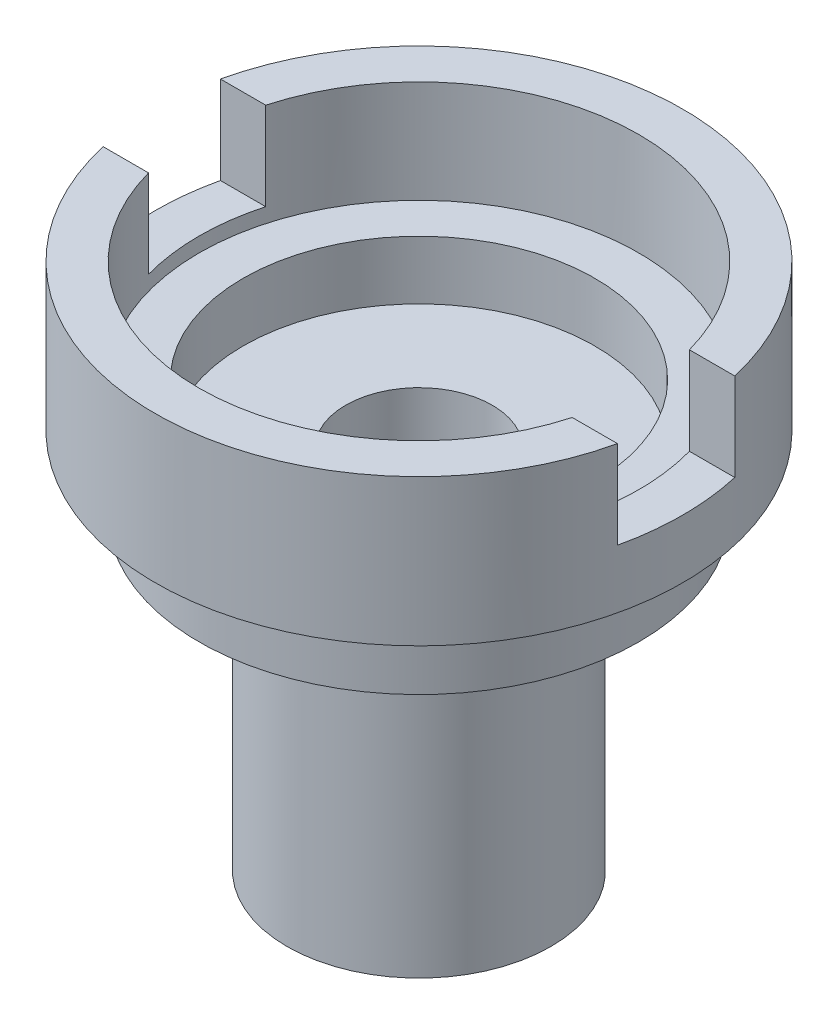
from build123d import *

# Parameters (mm, degrees)
SKETCH3_W          = 229.663439326
SKETCH3_H          = 40
CUT_EXTRUDE1_DEPTH = 30


with BuildPart() as part:
    # Sketch1 → Revolve1 (revolve)
    with BuildSketch(Plane.XY):
        Polygon((0, 0), (-45, 0), (-45, 105), (-75, 105), (-75, 130), (-90, 130), (-90, 180), (0, 180), align=None)
    revolve(axis=Axis((0, 209.327847516, 0), (0, -1, 0)))

    # Sketch2 → Cut-Revolve3 (revolve, cut)
    with BuildSketch(Plane.XY):
        Polygon((25, 0), (25, 125), (60, 125), (60, 145), (75, 145), (75, 180), (0, 180), (0, 0), align=None)
    revolve(axis=Axis((0, 180, 0), (0, -1, 0)), mode=Mode.SUBTRACT)

    # Sketch3 → Cut-Extrude1 (cut)
    with BuildSketch(Plane(origin=(0, 180, 0), x_dir=(1, 0, 0), z_dir=(0, 1, 0))):
        Rectangle(SKETCH3_W, SKETCH3_H)
    extrude(amount=-CUT_EXTRUDE1_DEPTH, mode=Mode.SUBTRACT)


solid = part.part
